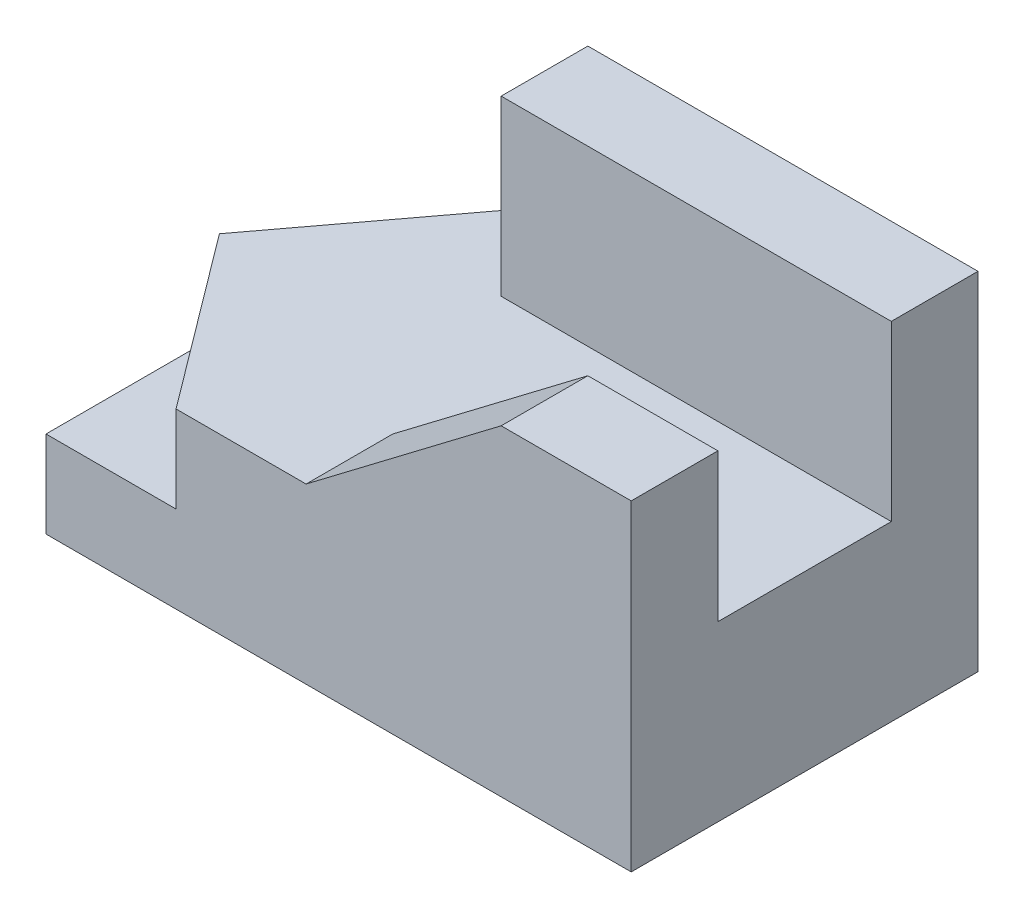
from build123d import *

# Parameters (mm, degrees)
SKETCH1_W           = 13.5
SKETCH1_H           = 8
BOSS_EXTRUDE1_DEPTH = 2
BOSS_EXTRUDE2_DEPTH = 2
SKETCH3_W           = 9
SKETCH3_H           = 2
SKETCH3_W_2         = 7.5
BOSS_EXTRUDE3_DEPTH = 4
CUT_EXTRUDE1_DEPTH  = 4


with BuildPart() as part:
    # Sketch1 → Boss-Extrude1 (new body)
    with BuildSketch(Plane(origin=(0, 0, 0), x_dir=(1, 0, 0), z_dir=(0, 1, 0))):
        Rectangle(SKETCH1_W, SKETCH1_H)
    extrude(amount=BOSS_EXTRUDE1_DEPTH)

    # Sketch2 → Boss-Extrude2 (add)
    with BuildSketch(Plane(origin=(0, 2, 0), x_dir=(1, 0, 0), z_dir=(0, 1, 0))):
        Polygon((-6.75, 0), (-3.75, 4), (6.75, 4), (6.75, -4), (-3.75, -4), align=None)
    extrude(amount=BOSS_EXTRUDE2_DEPTH)

    # Sketch3 → Boss-Extrude3 (add)
    with BuildSketch(Plane(origin=(0, 4, 0), x_dir=(1, 0, 0), z_dir=(0, 1, 0))):
        with Locations((2.25, 3)):
            Rectangle(SKETCH3_W, SKETCH3_H)
        with Locations((3, -3)):
            Rectangle(SKETCH3_W_2, SKETCH3_H)
    extrude(amount=BOSS_EXTRUDE3_DEPTH)

    # Sketch4 → Cut-Extrude1 (cut)
    with BuildSketch(Plane.XY.offset(4)):
        Polygon((6.75, 7.413398543), (3.75, 7.413398543), (-0.75, 4), (-0.75, 8), (6.75, 8), align=None)
    extrude(amount=-CUT_EXTRUDE1_DEPTH, mode=Mode.SUBTRACT)


solid = part.part
